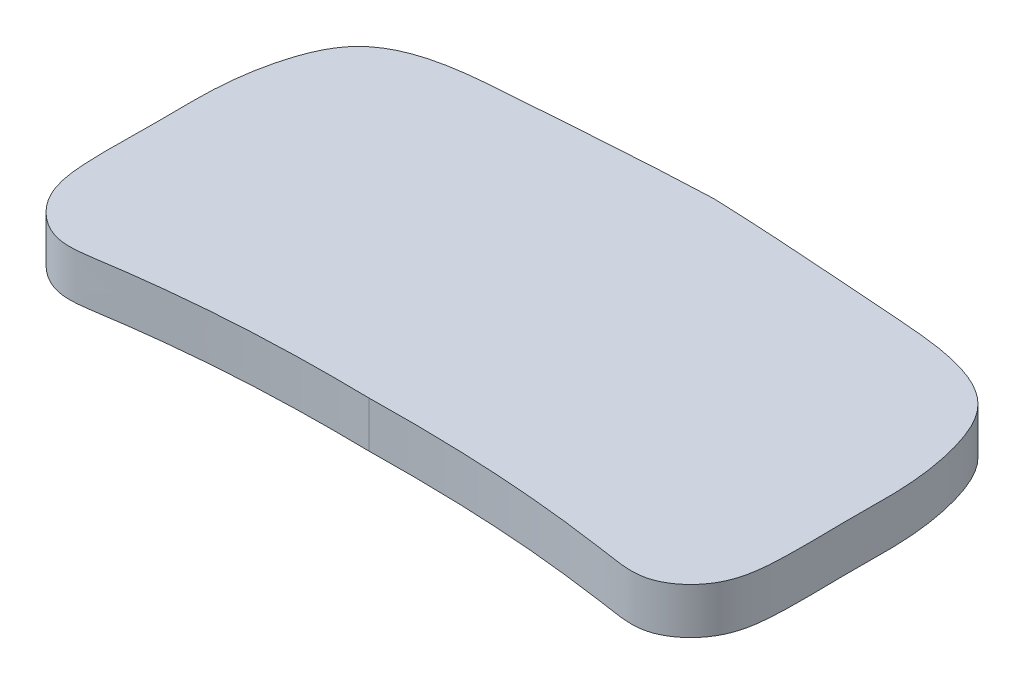
from build123d import *

# Parameters (mm, degrees)
Y_KSEKLIK_EKSTR_ZYON1_DEPTH = 4


with BuildPart() as part:
    # Çizim1 → Yükseklik-Ekstrüzyon1 (new body)
    with BuildSketch(Plane(origin=(0, 0, 0), x_dir=(1, 0, 0), z_dir=(0, 1, 0))):
        with BuildLine():
            add(Edge.make_bspline(
                [(0, 17.928841308), (-5.820212095, 17.709536244), (-13.903357487, 17.042587637), (-26.87571665, 16.196014495), (-29.550286899, 8.929250371), (-30.090469717, 4.336098712), (-29.940693307, -0.887353996), (-30.154927851, -5.701691423), (-29.637182829, -10.928766593), (-26.031174583, -14.081750554), (-15.720131404, -12.349312728), (-7.807226576, -11.938879102), (0, -12.071158692)],
                knots=[0, 0, 0, 0, 0.198459501, 0.336012796, 0.394476639, 0.459729731, 0.505376957, 0.582750838, 0.635932872, 0.690008906, 0.731880659, 1, 1, 1, 1], degree=3))
            add(Edge.make_bspline(
                [(0, 17.928841308), (5.820212095, 17.709536244), (13.903357487, 17.042587637), (26.87571665, 16.196014495), (29.550286899, 8.929250371), (30.090469717, 4.336098712), (29.940693307, -0.887353996), (30.154927851, -5.701691423), (29.637182829, -10.928766593), (26.031174583, -14.081750554), (15.720131404, -12.349312728), (7.807226576, -11.938879102), (0, -12.071158692)],
                knots=[0, 0, 0, 0, 0.198459501, 0.336012796, 0.394476639, 0.459729731, 0.505376957, 0.582750838, 0.635932872, 0.690008906, 0.731880659, 1, 1, 1, 1], degree=3))
        make_face()
    extrude(amount=Y_KSEKLIK_EKSTR_ZYON1_DEPTH)


solid = part.part
